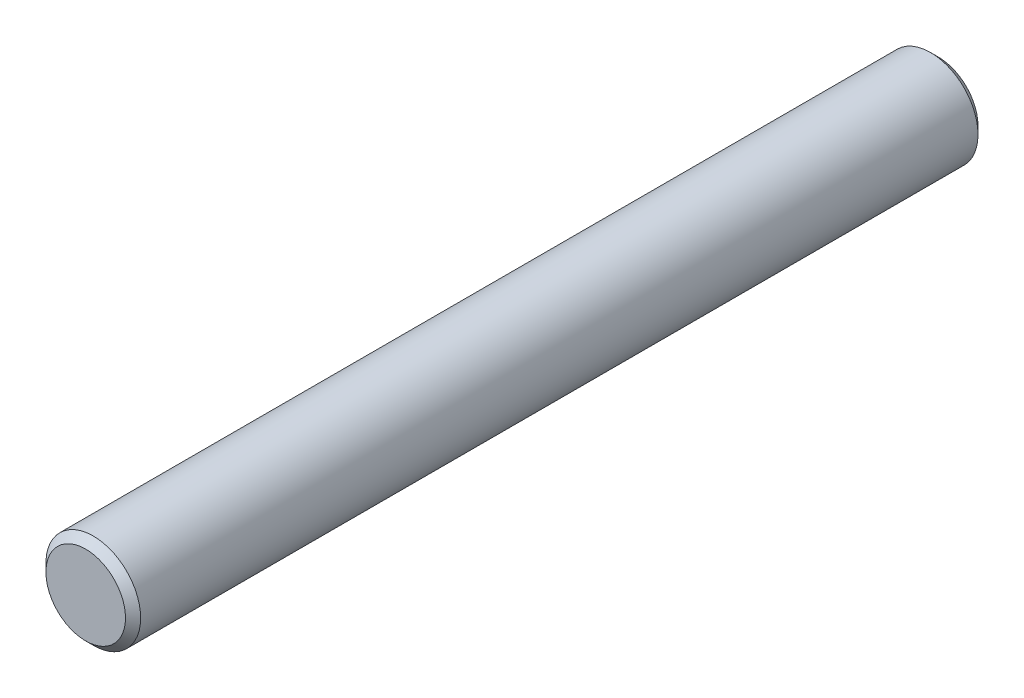
from build123d import *

# Parameters (mm, degrees)
SKETCH1_R           = 2.5
BOSS_EXTRUDE1_DEPTH = 45
CHAMFER1_SIZE       = 0.4


with BuildPart() as part:
    # Sketch1 → Boss-Extrude1 (new body)
    with BuildSketch(Plane.XY):
        Circle(SKETCH1_R)
    extrude(amount=BOSS_EXTRUDE1_DEPTH)

    # Chamfer1
    chamfer1_edges = [part.edges().sort_by_distance(p)[0] for p in [
        (-2.5, 0, 0),
        (-2.5, 0, 45),
    ]]
    chamfer(chamfer1_edges, length=CHAMFER1_SIZE)


solid = part.part
